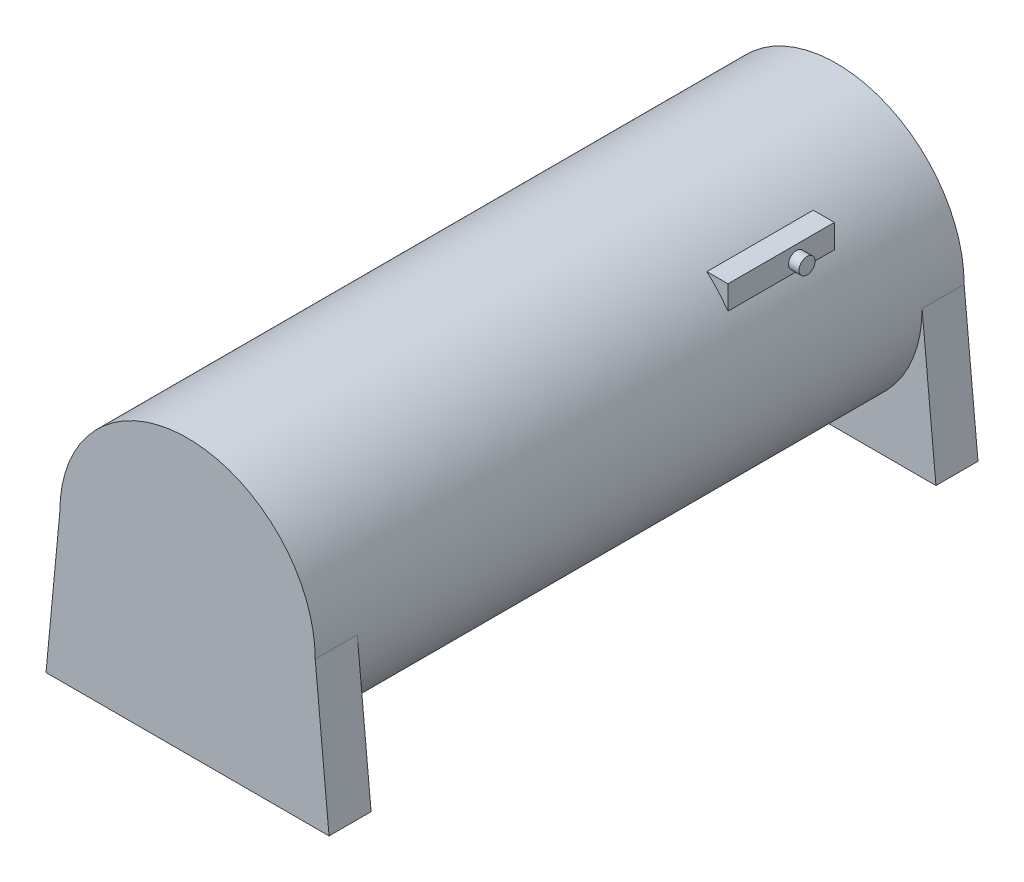
from build123d import *

# Parameters (mm, degrees)
SKETCH1_R           = 60.72
BOSS_EXTRUDE1_DEPTH = 308.6
BOSS_EXTRUDE2_DEPTH = 20
BOSS_EXTRUDE3_DEPTH = 20
SKETCH4_W           = 50.6
SKETCH4_H           = 12.7
BOSS_EXTRUDE4_DEPTH = 20
SKETCH5_R           = 3.8
BOSS_EXTRUDE5_DEPTH = 5


with BuildPart() as part:
    # Sketch1 → Boss-Extrude1 (new body)
    with BuildSketch(Plane.XY):
        Circle(SKETCH1_R)
    extrude(amount=BOSS_EXTRUDE1_DEPTH)

    # Sketch2 → Boss-Extrude2 (add)
    with BuildSketch(Plane.XY.offset(308.6)):
        Polygon((67.3, -69.512383737), (-67.3, -69.512383737), (-60.72, 0), (60.72, 0), align=None)
    extrude(amount=-BOSS_EXTRUDE2_DEPTH)

    # Sketch3 → Boss-Extrude3 (add)
    with BuildSketch(Plane(origin=(0, 0, 0), x_dir=(-1, 0, 0), z_dir=(0, 0, -1))):
        Polygon((2.236970423, -69.512383737), (-67.3, -69.512383737), (-60.72, 0), (60.72, 0), (67.3, -69.512383737), align=None)
    extrude(amount=-BOSS_EXTRUDE3_DEPTH)

    # Sketch4 → Boss-Extrude4 (add)
    with BuildSketch(Plane(origin=(50, 0, 0), x_dir=(0, 0, -1), z_dir=(1, 0, 0))):
        with Locations((-76.3, 39.37)):
            Rectangle(SKETCH4_W, SKETCH4_H)
    extrude(amount=-BOSS_EXTRUDE4_DEPTH)

    # Sketch5 → Boss-Extrude5 (add)
    with BuildSketch(Plane(origin=(50, 0, 0), x_dir=(0, 0, -1), z_dir=(1, 0, 0))):
        with Locations((-69, 39.37)):
            Circle(SKETCH5_R)
    extrude(amount=BOSS_EXTRUDE5_DEPTH)


solid = part.part
